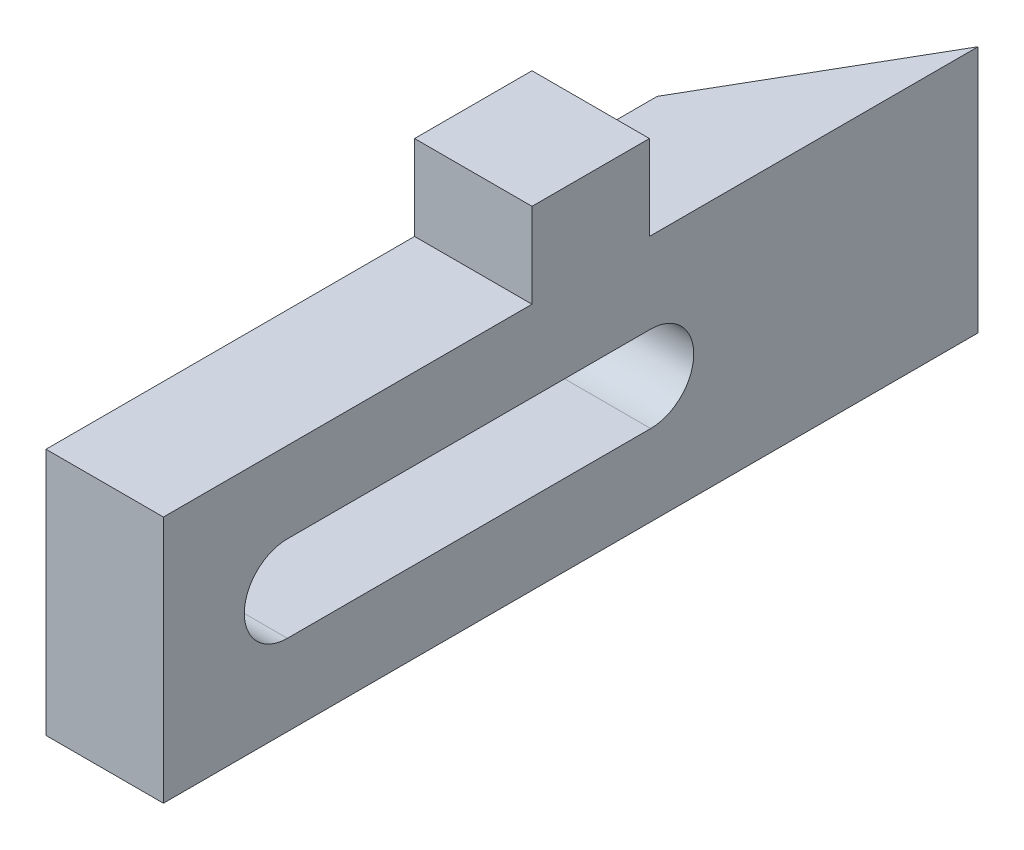
from build123d import *

# Parameters (mm, degrees)
BOSS_EXTRUDE1_DEPTH = 19
CUT_EXTRUDE1_DEPTH  = 10
SKETCH4_W           = 9
SKETCH4_H           = 9
BOSS_EXTRUDE3_DEPTH = 6.5


with BuildPart() as part:
    # Sketch1 → Boss-Extrude1 (new body)
    with BuildSketch(Plane(origin=(0, 0, 0), x_dir=(1, 0, 0), z_dir=(0, 1, 0))):
        Polygon((15.5, 26.846787517), (15.5, -20), (24.5, -20), (24.5, 42.435244785), align=None)
    extrude(amount=BOSS_EXTRUDE1_DEPTH)

    # Sketch3 → Cut-Extrude1 (cut, through all)
    with BuildSketch(Plane.ZY.offset(-15.5)):
        with BuildLine():
            Line((-17.346787517, 12.8), (10.5, 12.8))
            ThreePointArc((10.5, 12.8), (13.8, 9.5), (10.5, 6.2))
            Line((10.5, 6.2), (-17.346787517, 6.2))
            ThreePointArc((-17.346787517, 6.2), (-20.646787517, 9.5), (-17.346787517, 12.8))
        make_face()
    extrude(amount=-CUT_EXTRUDE1_DEPTH, mode=Mode.SUBTRACT)

    # Sketch4 → Boss-Extrude3 (add)
    with BuildSketch(Plane(origin=(0, 19, 0), x_dir=(1, 0, 0), z_dir=(0, 1, 0))):
        with Locations((20, 12.75)):
            Rectangle(SKETCH4_W, SKETCH4_H)
    extrude(amount=BOSS_EXTRUDE3_DEPTH)


solid = part.part
